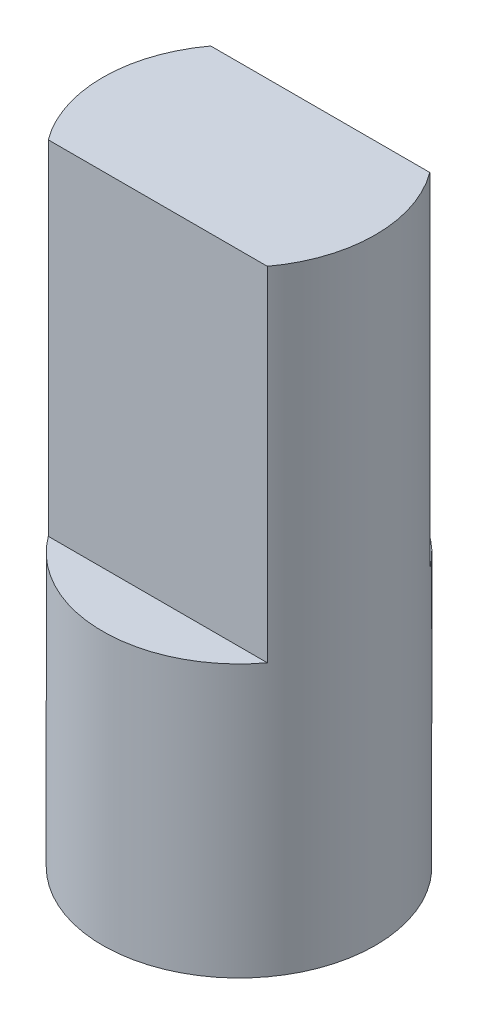
from build123d import *

# Parameters (mm, degrees)
BOSS_EXTRUDE1_DEPTH = 6.1722
SKETCH3_R           = 2.4511
BOSS_EXTRUDE2_DEPTH = 4.8895


with BuildPart() as part:
    # Sketch2 → Boss-Extrude1 (new body)
    with BuildSketch(Plane(origin=(0, 0, 0), x_dir=(1, 0, 0), z_dir=(0, 1, 0))):
        with BuildLine():
            Line((-1.968459032, 1.4605), (1.968459032, 1.4605))
            ThreePointArc((1.968459032, 1.4605), (2.4511, 0), (1.968459032, -1.4605))
            Line((1.968459032, -1.4605), (-1.968459032, -1.4605))
            ThreePointArc((-1.968459032, -1.4605), (-2.4511, 0), (-1.968459032, 1.4605))
        make_face()
    extrude(amount=-BOSS_EXTRUDE1_DEPTH)

    # Sketch3 → Boss-Extrude2 (add)
    with BuildSketch(Plane.XZ.offset(6.1722)):
        Circle(SKETCH3_R)
    extrude(amount=BOSS_EXTRUDE2_DEPTH)


solid = part.part
